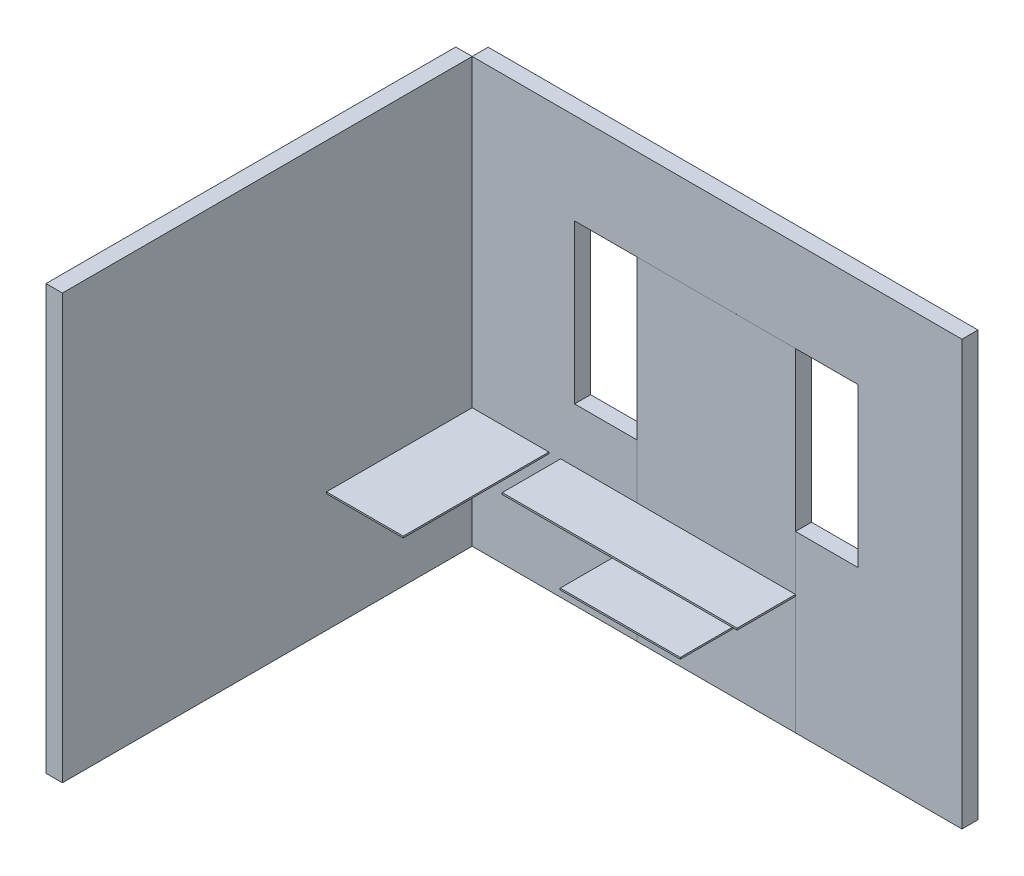
from build123d import *

# Parameters (mm, degrees)
ESBO_O6_W                = 3060
ESBO_O6_H                = 2650
RESSALTO_EXTRUS_O2_DEPTH = 100
ESBO_O7_W                = 390
ESBO_O7_H                = 990
CORTE_EXTRUS_O1_DEPTH    = 749
ESBO_O8_W                = 102.431246956
ESBO_O8_H                = 2650
RESSALTO_EXTRUS_O3_DEPTH = 2560
ESBO_O9_W                = 479.151961804
ESBO_O9_H                = 10
RESSALTO_EXTRUS_O5_DEPTH = 910
RESSALTO_EXTRUS_O7_DEPTH = 365
ESBO_O13_W               = 990
ESBO_O13_H               = 1330.610148593
RESSALTO_EXTRUS_O8_DEPTH = 0.01
ESBO_O14_W               = 750
ESBO_O14_H               = 10
RESSALTO_EXTRUS_O9_DEPTH = 600


with BuildPart() as part:
    # Esboço6 → Ressalto-extrusão2 (new body)
    with BuildSketch(Plane.XY):
        with Locations((1530, 1325)):
            Rectangle(ESBO_O6_W, ESBO_O6_H)
    extrude(amount=RESSALTO_EXTRUS_O2_DEPTH)

    # Esboço7 → Corte-extrusão1 (cut)
    with BuildSketch(Plane.XY.offset(100)):
        with Locations((2215, 1585)):
            Rectangle(ESBO_O7_W, ESBO_O7_H)
        with Locations((835, 1585)):
            Rectangle(ESBO_O7_W, ESBO_O7_H)
    extrude(amount=-CORTE_EXTRUS_O1_DEPTH, mode=Mode.SUBTRACT)

    # Esboço12 → Ressalto-extrusão7 (add)
    with BuildSketch(Plane.XY.offset(100)):
        Polygon((552.866885131, 749.389851407), (2020, 749.389851407), (2020, 738.547480568), (552.866885131, 738.743736065), align=None)
    extrude(amount=RESSALTO_EXTRUS_O7_DEPTH)

    # Esboço13 → Ressalto-extrusão8 (add)
    with BuildSketch(Plane.XY.offset(100)):
        with Locations((1525, 1414.694925704)):
            Rectangle(ESBO_O13_W, ESBO_O13_H)
        Polygon((2020, 738.547480568), (2020, 0), (1030, 0), (1030, 738.679910911), align=None)
    extrude(amount=RESSALTO_EXTRUS_O8_DEPTH)

    # Esboço14 → Ressalto-extrusão9 (add)
    with BuildSketch(Plane.XY.offset(100.01)):
        with Locations((1525, 643.61369574)):
            Rectangle(ESBO_O14_W, ESBO_O14_H)
    extrude(amount=RESSALTO_EXTRUS_O9_DEPTH)


with BuildPart() as body_2:
    # Esboço8 → Ressalto-extrusão3 (new body)
    with BuildSketch(Plane.XY.offset(100)):
        with Locations((-51.215623478, 1325)):
            Rectangle(ESBO_O8_W, ESBO_O8_H)
    extrude(amount=RESSALTO_EXTRUS_O3_DEPTH)


with BuildPart() as body_3:
    # Esboço9 → Ressalto-extrusão5 (new body)
    with BuildSketch(Plane.XY.offset(100)):
        with Locations((239.575980902, 744.389851407)):
            Rectangle(ESBO_O9_W, ESBO_O9_H)
    extrude(amount=RESSALTO_EXTRUS_O5_DEPTH)


solid = Compound([part.part, body_2.part, body_3.part])
